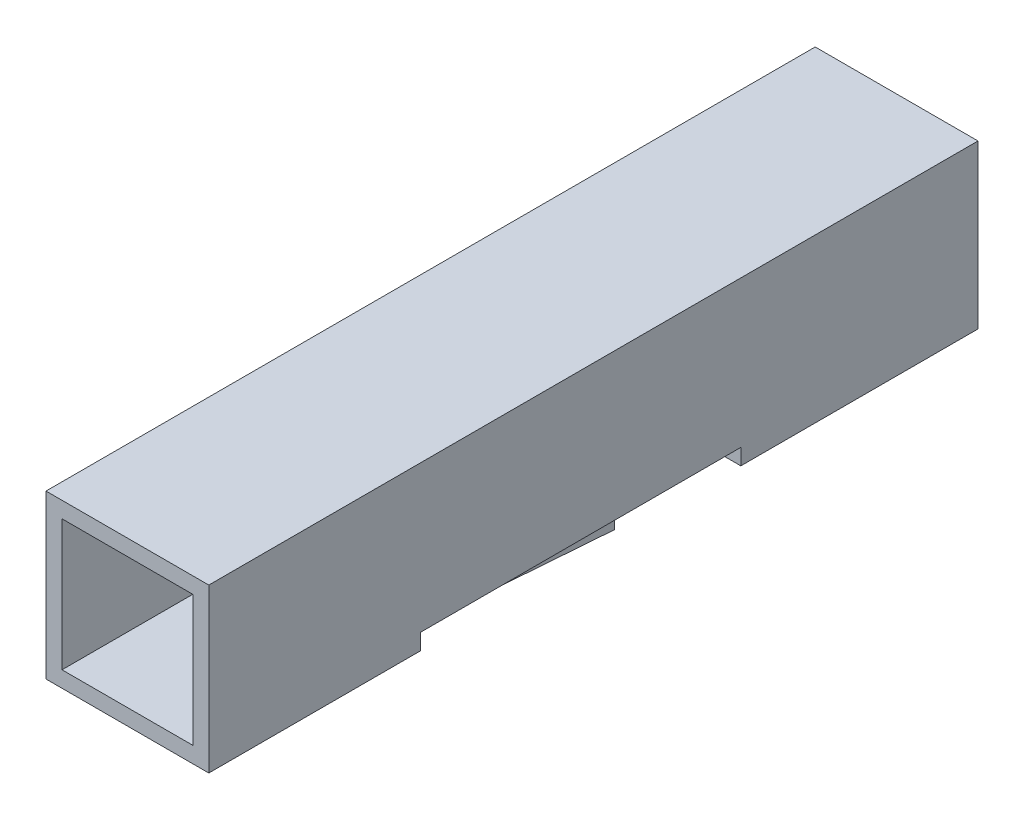
from build123d import *

# Parameters (mm, degrees)
SKETCH1_W           = 2.54
SKETCH1_H           = 2.54
SKETCH1_W_2         = 1.14
SKETCH1_H_2         = 1.14
BOSS_EXTRUDE1_DEPTH = 12
SKETCH2_W           = 2.04
SKETCH2_H           = 2.04
CUT_EXTRUDE1_DEPTH  = 11.5
CHAMFER1_SIZE       = 0.3
SKETCH3_W           = 2.54
SKETCH3_H           = 5
CUT_EXTRUDE2_DEPTH  = 0.25
BOSS_EXTRUDE2_DEPTH = 0.9


with BuildPart() as part:
    # Sketch1 → Boss-Extrude1 (new body)
    with BuildSketch(Plane.XY):
        Rectangle(SKETCH1_W, SKETCH1_H)
        Rectangle(SKETCH1_W_2, SKETCH1_H_2, mode=Mode.SUBTRACT)
    extrude(amount=BOSS_EXTRUDE1_DEPTH)

    # Sketch2 → Cut-Extrude1 (cut)
    with BuildSketch(Plane.XY.offset(12)):
        Rectangle(SKETCH2_W, SKETCH2_H)
    extrude(amount=-CUT_EXTRUDE1_DEPTH, mode=Mode.SUBTRACT)

    # Chamfer1
    chamfer1_edges = [part.edges().sort_by_distance(p)[0] for p in [
        (0.57, 0, 0),
        (0, 0.57, 0),
        (-0.57, 0, 0),
        (0, -0.57, 0),
    ]]
    chamfer(chamfer1_edges, length=CHAMFER1_SIZE)

    # Sketch3 → Cut-Extrude2 (cut)
    with BuildSketch(Plane.XZ.offset(1.27)):
        with Locations((0, 6.2)):
            Rectangle(SKETCH3_W, SKETCH3_H)
    extrude(amount=-CUT_EXTRUDE2_DEPTH, mode=Mode.SUBTRACT)

    # Sketch4 → Boss-Extrude2 (add, symmetric)
    with BuildSketch(Plane(origin=(0, 0, 0), x_dir=(0, 0, -1), z_dir=(1, 0, 0))):
        Polygon((-5.3, -1.51689304), (-5.3, -0.798560217), (-8.7, -1.02), (-8.7, -1.27), align=None)
    extrude(amount=BOSS_EXTRUDE2_DEPTH, both=True)


solid = part.part
